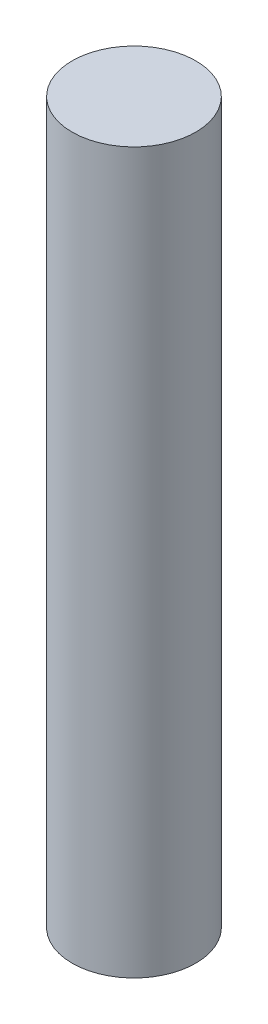
from build123d import *

# Parameters (mm, degrees)
SKETCH1_R           = 3.68046
BOSS_EXTRUDE1_DEPTH = 42.8625


with BuildPart() as part:
    # Sketch1 → Boss-Extrude1 (new body)
    with BuildSketch(Plane(origin=(0, 0, 0), x_dir=(1, 0, 0), z_dir=(0, 1, 0))):
        Circle(SKETCH1_R)
    extrude(amount=BOSS_EXTRUDE1_DEPTH)


solid = part.part
